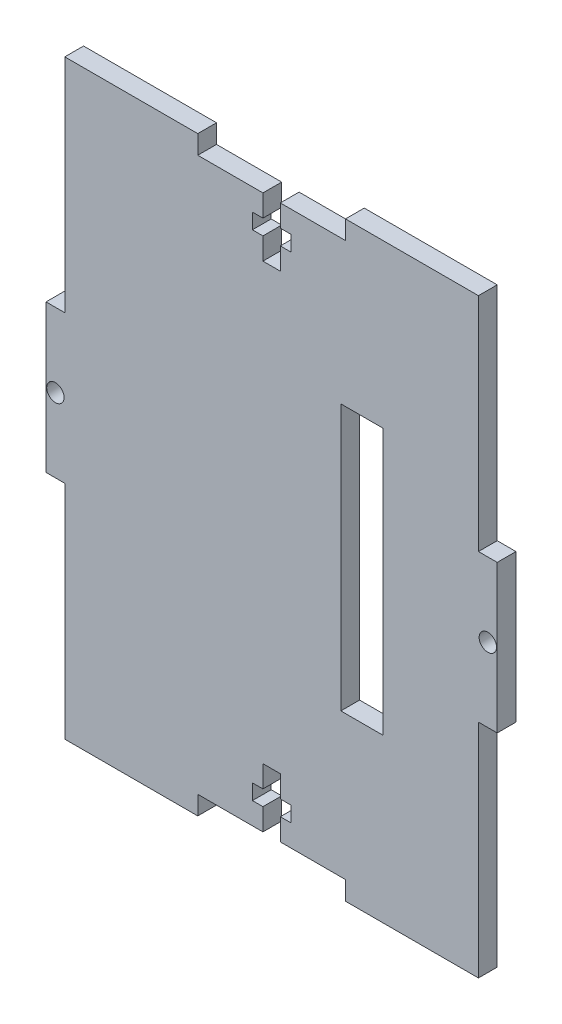
from build123d import *

# Parameters (mm, degrees)
SKETCH1_R           = 1.47
BOSS_EXTRUDE1_DEPTH = 1.5875
SKETCH3_W           = 7.175
SKETCH3_H           = 45
CUT_EXTRUDE1_DEPTH  = 4.175


with BuildPart() as part:
    # Sketch1 → Boss-Extrude1 (new body, symmetric)
    with BuildSketch(Plane.XY):
        Polygon((-12.5, 50), (-35, 50), (-35, 12.5), (-38.175, 12.5), (-38.175, -12.5), (-35, -12.5), (-35, -50), (-12.5, -50), (-12.5, -46.825), (-1.47, -46.825), (-1.47, -43.125), (-3.25, -43.125), (-3.25, -40.525), (-1.47, -40.525), (-1.47, -36.825), (1.47, -36.825), (1.47, -40.525), (3.25, -40.525), (3.25, -43.125), (1.47, -43.125), (1.47, -46.825), (12.5, -46.825), (12.5, -50), (35, -50), (35, -12.5), (38.175, -12.5), (38.175, 12.5), (35, 12.5), (35, 50), (12.5, 50), (12.5, 46.825), (1.47, 46.825), (1.47, 43.125), (3.25, 43.125), (3.25, 40.525), (1.47, 40.525), (1.47, 36.825), (-1.47, 36.825), (-1.47, 40.525), (-3.25, 40.525), (-3.25, 43.125), (-1.47, 43.125), (-1.47, 46.825), (-12.5, 46.825), align=None)
        with Locations((-36.5875, 0)):
            Circle(SKETCH1_R, mode=Mode.SUBTRACT)
        with Locations((36.5875, 0)):
            Circle(SKETCH1_R, mode=Mode.SUBTRACT)
    extrude(amount=BOSS_EXTRUDE1_DEPTH, both=True)

    # Sketch3 → Cut-Extrude1 (cut, through all)
    with BuildSketch(Plane(origin=(0, 0, -1.5875), x_dir=(-1, 0, 0), z_dir=(0, 0, -1))):
        with Locations((-15.3, 0)):
            Rectangle(SKETCH3_W, SKETCH3_H)
    extrude(amount=-CUT_EXTRUDE1_DEPTH, mode=Mode.SUBTRACT)


solid = part.part
